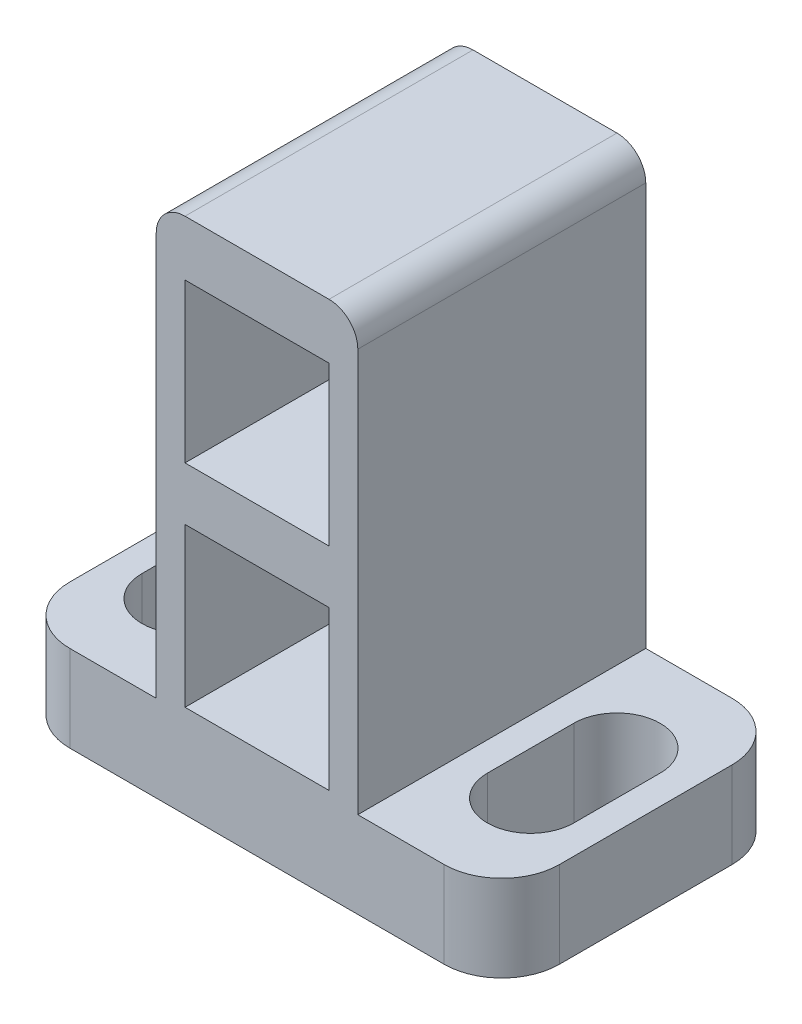
from build123d import *

# Parameters (mm, degrees)
SKETCH1_W            = 7
SKETCH1_H            = 18
BOSS_EXTRUDE1_DEPTH  = 8
SKETCH3_W            = 7
SKETCH3_H            = 18
BOSS_EXTRUDE2_DEPTH  = 2
SKETCH2_W            = 5
SKETCH2_H            = 5.5
CUT_EXTRUDE1_DEPTH   = 8
SKETCH4_R            = 1
CUT_EXTRUDE2_DEPTH   = 3
SKETCH5_W            = 5
SKETCH5_H            = 10
BOSS_EXTRUDE3_DEPTH  = 3
FILLET1_R            = 2
FILLET1_OF_MIRROR2_R = 2
FILLET2_R            = 1


with BuildPart() as part:
    # Sketch1 → Boss-Extrude1 (new body)
    with BuildSketch(Plane.XY):
        Rectangle(SKETCH1_W, SKETCH1_H)
    extrude(amount=BOSS_EXTRUDE1_DEPTH)

    # Sketch3 → Boss-Extrude2 (add)
    with BuildSketch(Plane(origin=(0, 0, 0), x_dir=(-1, 0, 0), z_dir=(0, 0, -1))):
        Rectangle(SKETCH3_W, SKETCH3_H)
    extrude(amount=BOSS_EXTRUDE2_DEPTH)

    # Sketch2 → Cut-Extrude1 (cut)
    with BuildSketch(Plane.XY.offset(8)):
        with Locations((0, 4.33)):
            Rectangle(SKETCH2_W, SKETCH2_H)
        with Locations((0, -3.02)):
            Rectangle(SKETCH2_W, SKETCH2_H)
    extrude(amount=-CUT_EXTRUDE1_DEPTH, mode=Mode.SUBTRACT)

    # Sketch4 → Cut-Extrude2 (cut, through all)
    with BuildSketch(Plane.XY):
        with Locations((0, 4.33)):
            Circle(SKETCH4_R)
        with Locations((0, -3.02)):
            Circle(SKETCH4_R)
    extrude(amount=-CUT_EXTRUDE2_DEPTH, mode=Mode.SUBTRACT)

    # Sketch5 → Boss-Extrude3 (add)
    with BuildSketch(Plane.XZ.offset(9)):
        with Locations((6, 3)):
            Rectangle(SKETCH5_W, SKETCH5_H)
        with BuildLine():
            Line((7.5, 4.5), (7.5, 1.5))
            ThreePointArc((7.5, 1.5), (6, 0), (4.5, 1.5))
            Line((4.5, 1.5), (4.5, 4.5))
            ThreePointArc((4.5, 4.5), (6, 6), (7.5, 4.5))
        make_face(mode=Mode.SUBTRACT)
    boss_extrude3 = extrude(amount=-BOSS_EXTRUDE3_DEPTH)

    # Fillet1
    fillet1_edges = [part.edges().sort_by_distance(p)[0] for p in [
        (8.5, -7.5, -2),
        (8.5, -7.5, 8),
    ]]
    fillet(fillet1_edges, radius=FILLET1_R)

    # Mirror2: Boss-Extrude3 across plane
    add(boss_extrude3.mirror(Plane(origin=(0, 0, 0), x_dir=(0, 0, 1), z_dir=(1, 0, 0))))

    # Fillet1 of Mirror2
    fillet1_of_mirror2_edges = [part.edges().sort_by_distance(p)[0] for p in [
        (-8.5, -7.5, -2),
        (-8.5, -7.5, 8),
    ]]
    fillet(fillet1_of_mirror2_edges, radius=FILLET1_OF_MIRROR2_R)

    # Fillet2
    fillet2_edges = [part.edges().sort_by_distance(p)[0] for p in [
        (3.5, 9, 3),
        (-3.5, 9, 3),
    ]]
    fillet(fillet2_edges, radius=FILLET2_R)


solid = part.part
